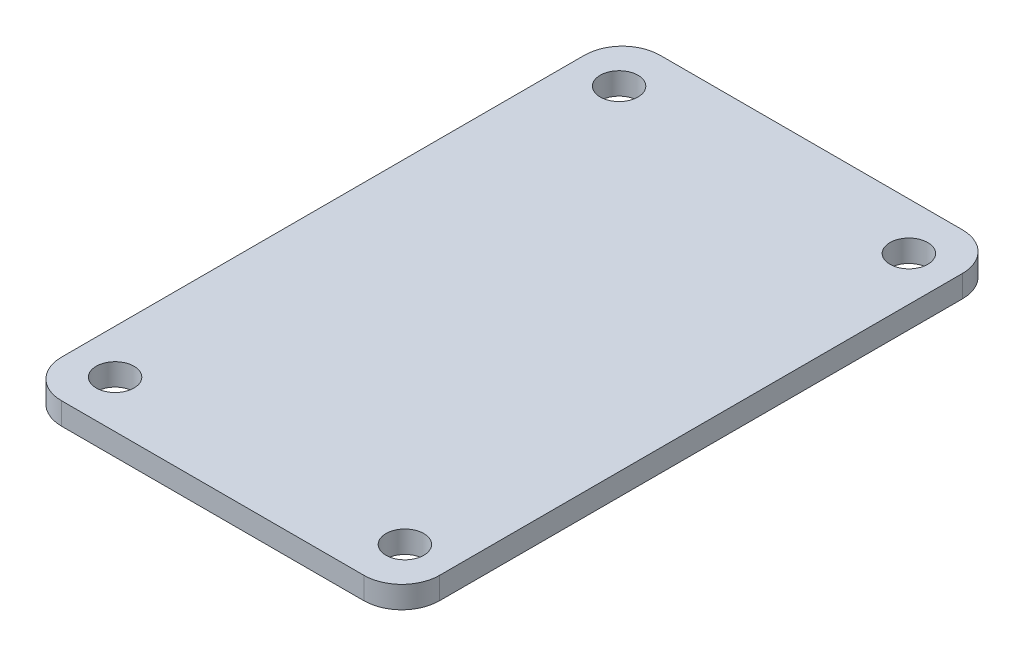
from build123d import *

# Parameters (mm, degrees)
SKETCH1_R           = 1.5
BOSS_EXTRUDE1_DEPTH = 1.75


with BuildPart() as part:
    # Sketch1 → Boss-Extrude1 (new body)
    with BuildSketch(Plane(origin=(0, 0, 0), x_dir=(1, 0, 0), z_dir=(0, 1, 0))):
        with BuildLine():
            Line((-12, -23.75), (12, -23.75))
            ThreePointArc((12, -23.75), (14.121320344, -22.871320344), (15, -20.75))
            Line((15, -20.75), (15, 20.75))
            ThreePointArc((15, 20.75), (14.121320344, 22.871320344), (12, 23.75))
            Line((12, 23.75), (-12, 23.75))
            ThreePointArc((-12, 23.75), (-14.121320344, 22.871320344), (-15, 20.75))
            Line((-15, 20.75), (-15, -20.75))
            ThreePointArc((-15, -20.75), (-14.121320344, -22.871320344), (-12, -23.75))
        make_face()
        with Locations((-11.5, 20)):
            Circle(SKETCH1_R, mode=Mode.SUBTRACT)
        with Locations((11.5, 20)):
            Circle(SKETCH1_R, mode=Mode.SUBTRACT)
        with Locations((11.5, -20)):
            Circle(SKETCH1_R, mode=Mode.SUBTRACT)
        with Locations((-11.5, -20)):
            Circle(SKETCH1_R, mode=Mode.SUBTRACT)
    extrude(amount=BOSS_EXTRUDE1_DEPTH)


solid = part.part
